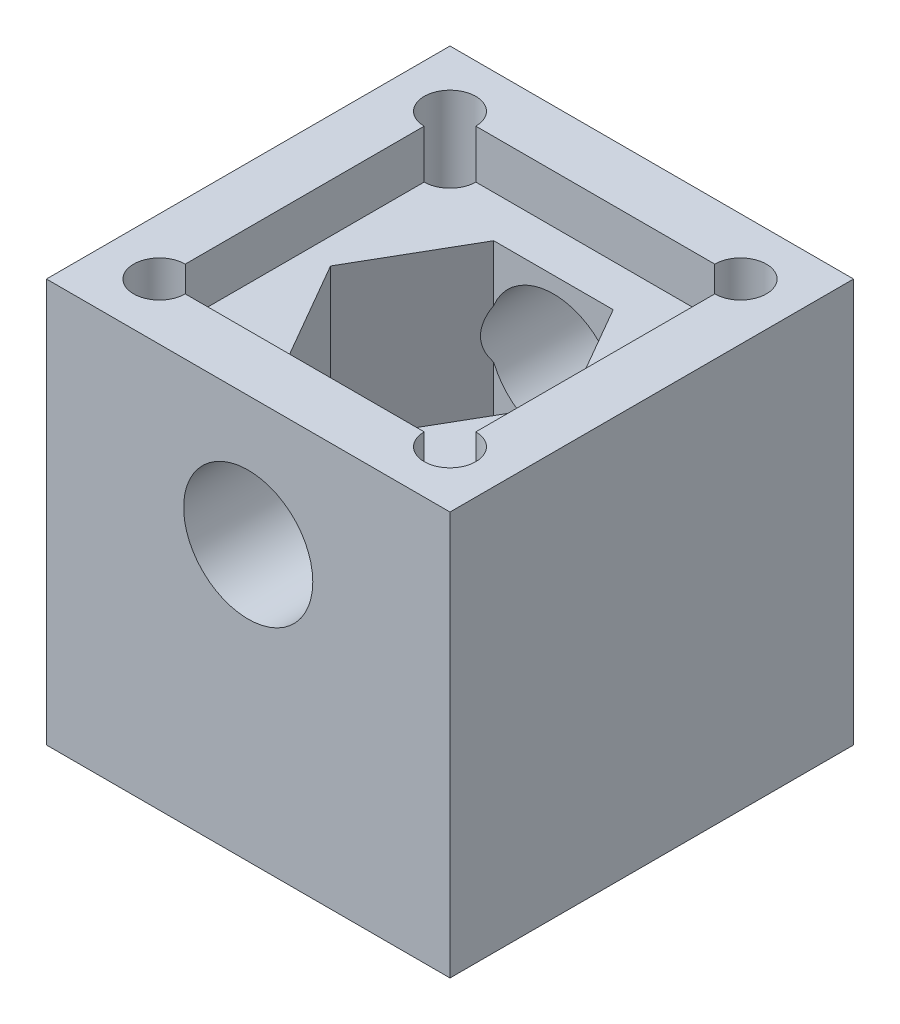
from build123d import *

# Parameters (mm, degrees)
SKETCH1_W           = 25
SKETCH1_H           = 25
BOSS_EXTRUDE1_DEPTH = 25
SKETCH2_R           = 4
CUT_EXTRUDE1_DEPTH  = 26
SKETCH4_R           = 4.15
CUT_EXTRUDE2_DEPTH  = 26
CUT_EXTRUDE3_DEPTH  = 18
SKETCH6_R           = 1.6
CUT_EXTRUDE4_DEPTH  = 26
SKETCH7_W           = 18
SKETCH7_H           = 18
CUT_EXTRUDE5_DEPTH  = 3


with BuildPart() as part:
    # Sketch1 → Boss-Extrude1 (new body)
    with BuildSketch(Plane(origin=(0, 0, 0), x_dir=(1, 0, 0), z_dir=(0, 1, 0))):
        Rectangle(SKETCH1_W, SKETCH1_H)
    extrude(amount=BOSS_EXTRUDE1_DEPTH)

    # Sketch2 → Cut-Extrude1 (cut, through all)
    with BuildSketch(Plane.XY.offset(12.5)):
        with Locations((0, 17)):
            Circle(SKETCH2_R)
    extrude(amount=-CUT_EXTRUDE1_DEPTH, mode=Mode.SUBTRACT)

    # Sketch4 → Cut-Extrude2 (cut, through all)
    with BuildSketch(Plane(origin=(0, 25, 0), x_dir=(1, 0, 0), z_dir=(0, 1, 0))):
        with Locations(Location((0, 0, 0), (0, 0, 270))):  # turned: the seam where the file's is
            Circle(SKETCH4_R)
    extrude(amount=-CUT_EXTRUDE2_DEPTH, mode=Mode.SUBTRACT)

    # Sketch5 → Cut-Extrude3 (cut)
    with BuildSketch(Plane(origin=(0, 25, 0), x_dir=(1, 0, 0), z_dir=(0, 1, 0))):
        Polygon((-3.7, -6.408587988), (3.7, -6.408587988), (7.4, 0), (3.7, 6.408587988), (-3.7, 6.408587988), (-7.4, 0), align=None)
    extrude(amount=-CUT_EXTRUDE3_DEPTH, mode=Mode.SUBTRACT)

    # Sketch6 → Cut-Extrude4 (cut, through all)
    with BuildSketch(Plane(origin=(0, 25, 0), x_dir=(1, 0, 0), z_dir=(0, 1, 0))):
        with Locations(Location((9, -9, 0), (0, 0, 270))):  # turned: the seam where the file's is
            Circle(SKETCH6_R)
        with Locations(Location((-9, -9, 0), (0, 0, 270))):  # turned: the seam where the file's is
            Circle(SKETCH6_R)
        with Locations(Location((-9, 9, 0), (0, 0, 270))):  # turned: the seam where the file's is
            Circle(SKETCH6_R)
        with Locations(Location((9, 9, 0), (0, 0, 270))):  # turned: the seam where the file's is
            Circle(SKETCH6_R)
    extrude(amount=-CUT_EXTRUDE4_DEPTH, mode=Mode.SUBTRACT)

    # Sketch7 → Cut-Extrude5 (cut)
    with BuildSketch(Plane(origin=(0, 25, 0), x_dir=(1, 0, 0), z_dir=(0, 1, 0))):
        Rectangle(SKETCH7_W, SKETCH7_H)
    extrude(amount=-CUT_EXTRUDE5_DEPTH, mode=Mode.SUBTRACT)


solid = part.part
